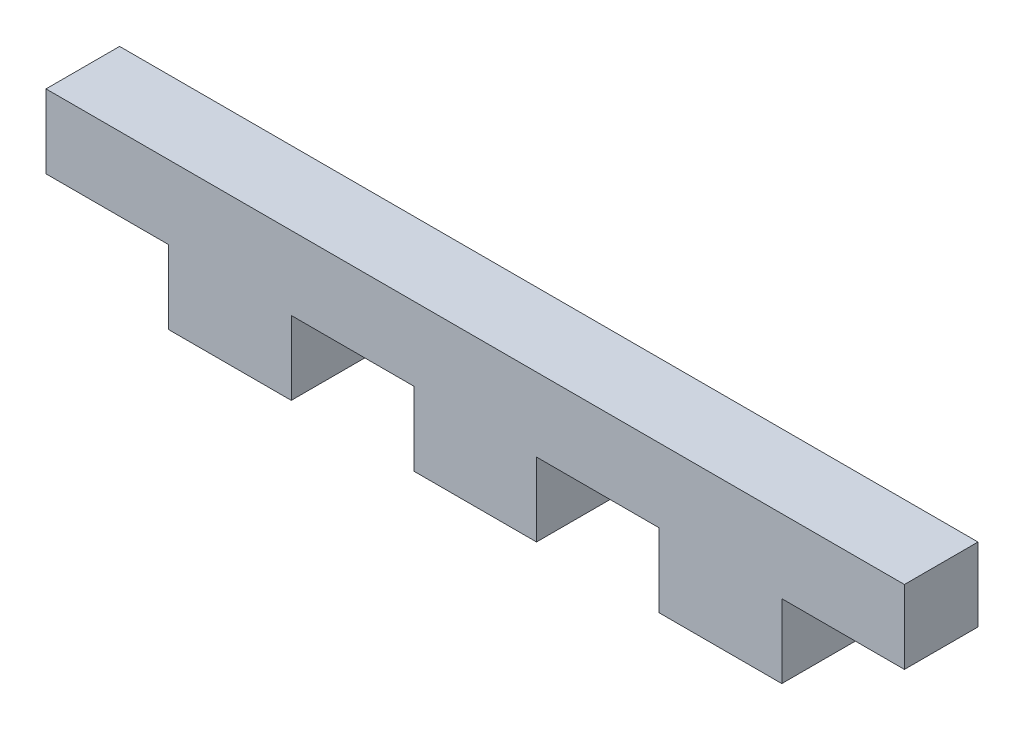
from build123d import *

# Parameters (mm, degrees)
BOSS_EXTRU_1_DEPTH = 3


with BuildPart() as part:
    # Esquisse1 → Boss.-Extru.1 (new body)
    with BuildSketch(Plane.XY):
        Polygon((18.990106642, -2.899569673), (18.990106642, 0.100430327), (23.990106642, 0.100430327), (23.990106642, -2.899569673), (28.990106642, -2.899569673), (28.990106642, 0.100430327), (33.990106642, 0.100430327), (33.990106642, 3.100430327), (-1.009893358, 3.100430327), (-1.009893358, 0.100430327), (3.990106642, 0.100430327), (3.990106642, -2.899569673), (8.990106642, -2.899569673), (8.990106642, 0.100430327), (13.990106642, 0.100430327), (13.990106642, -2.899569673), align=None)
    extrude(amount=BOSS_EXTRU_1_DEPTH)


solid = part.part
